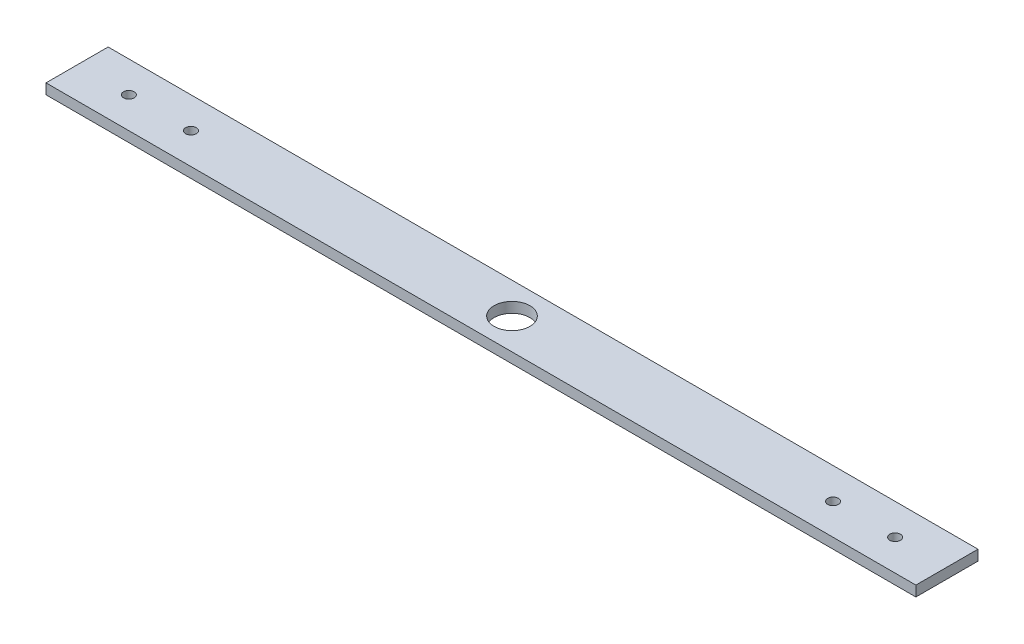
from build123d import *

# Parameters (mm, degrees)
SKETCH1_W                = 533.4
SKETCH1_H                = 38.1
BOSS_EXTRUDE1_DEPTH      = 6.35
SKETCH2_R                = 11
CUT_EXTRUDE1_DEPTH       = 7.62
F_0_257_DIAMETER_HOLE1_D = 6.5278


with BuildPart() as part:
    # Sketch1 → Boss-Extrude1 (new body)
    with BuildSketch(Plane(origin=(0, 0, 0), x_dir=(1, 0, 0), z_dir=(0, 1, 0))):
        Rectangle(SKETCH1_W, SKETCH1_H)
    extrude(amount=BOSS_EXTRUDE1_DEPTH)

    # Sketch2 → Cut-Extrude1 (cut)
    with BuildSketch(Plane(origin=(0, 6.35, 0), x_dir=(1, 0, 0), z_dir=(0, 1, 0))):
        Circle(SKETCH2_R)
    extrude(amount=-CUT_EXTRUDE1_DEPTH, mode=Mode.SUBTRACT)

    # F (0.257) Diameter Hole1 (through all)
    with Locations(Plane(origin=(0, 6.35, 0), x_dir=(1, 0, 0), z_dir=(0, 1, 0))):
        with Locations((234.95, 0), (196.85, 0)):
            f_0_257_diameter_hole1 = Hole(F_0_257_DIAMETER_HOLE1_D / 2)

    # Mirror1: F (0.257) Diameter Hole1 across plane
    add(f_0_257_diameter_hole1.mirror(Plane(origin=(0, 0, 0), x_dir=(0, 0, 1), z_dir=(1, 0, 0))), mode=Mode.SUBTRACT)


solid = part.part
